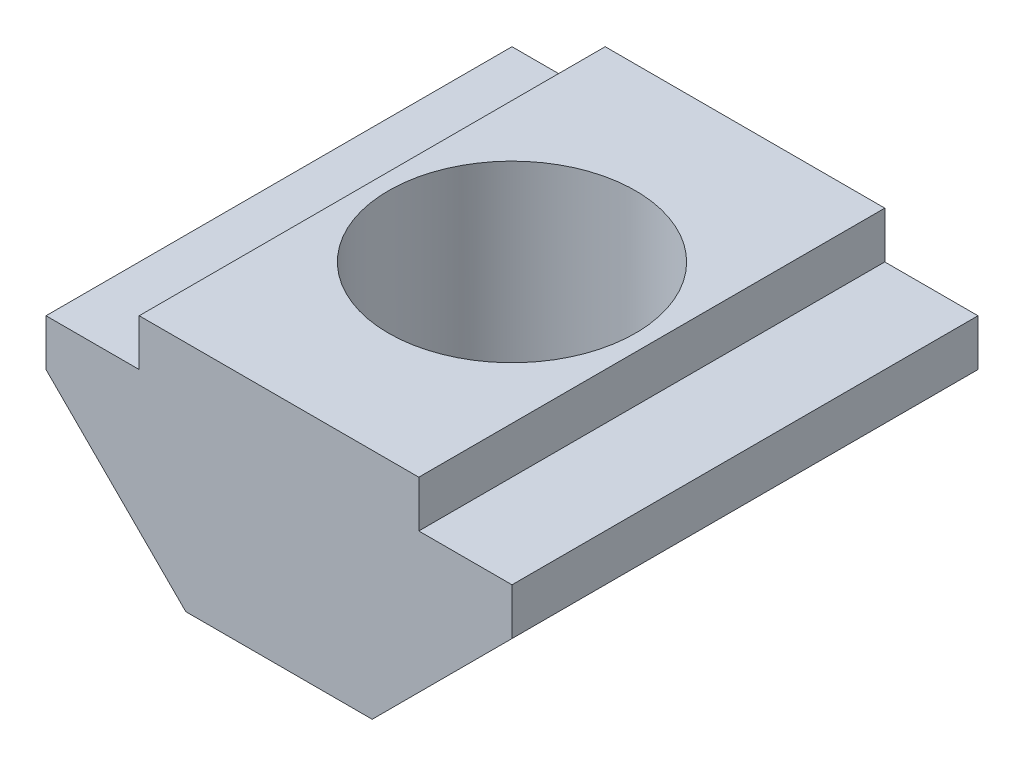
from build123d import *

# Parameters (mm, degrees)
BOSS_EXTRUDE1_DEPTH      = 5
BOSS_EXTRUDE1_DEPTH_BACK = 5
M5_CLEARANCE_HOLE1_D     = 5.3
M5_CLEARANCE_HOLE1_DEPTH = 23.08
M5_CLEARANCE_HOLE1_TIP   = 1.59228064


with BuildPart() as part:
    # Sketch1 → Boss-Extrude1 (new, two sides: drawn at the far end of the back side and taken through both)
    with BuildSketch(Plane.XY.offset(-BOSS_EXTRUDE1_DEPTH_BACK)):
        Polygon((3, 2.5), (-3, 2.5), (-3, 1.5), (-5, 1.5), (-5, 0.5), (-2, -2.5), (2, -2.5), (5, 0.5), (5, 1.5), (3, 1.5), align=None)
    extrude(amount=BOSS_EXTRUDE1_DEPTH + BOSS_EXTRUDE1_DEPTH_BACK)

    # M5 Clearance Hole1
    with Locations(Plane(origin=(0, 2.5, 0), x_dir=(1, 0, 0), z_dir=(0, 1, 0))):
        with Locations((0, 0)):
            Hole(M5_CLEARANCE_HOLE1_D / 2, depth=M5_CLEARANCE_HOLE1_DEPTH)
            with Locations((0, 0, -(M5_CLEARANCE_HOLE1_DEPTH + M5_CLEARANCE_HOLE1_TIP / 2))):  # 118° drill point
                Cone(0, M5_CLEARANCE_HOLE1_D / 2, M5_CLEARANCE_HOLE1_TIP, mode=Mode.SUBTRACT)


solid = part.part
